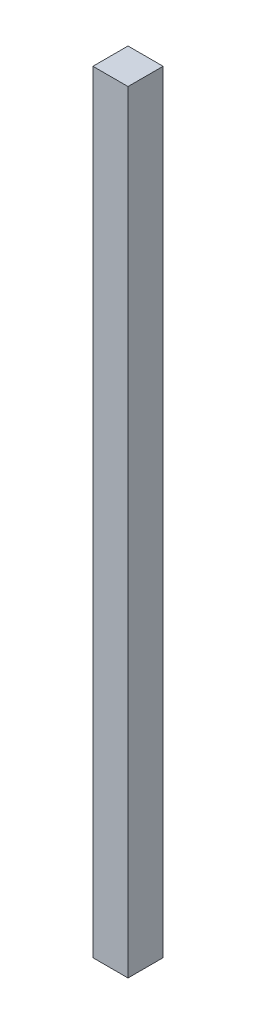
from build123d import *

# Parameters (mm, degrees)
SKETCH1_W           = 25.4
SKETCH1_H           = 25.4
BOSS_EXTRUDE1_DEPTH = 558.8


with BuildPart() as part:
    # Sketch1 → Boss-Extrude1 (new body)
    with BuildSketch(Plane(origin=(0, 0, 0), x_dir=(1, 0, 0), z_dir=(0, 1, 0))):
        with Locations((-29.032437983, 19.429234924)):
            Rectangle(SKETCH1_W, SKETCH1_H)
    extrude(amount=BOSS_EXTRUDE1_DEPTH)


solid = part.part
